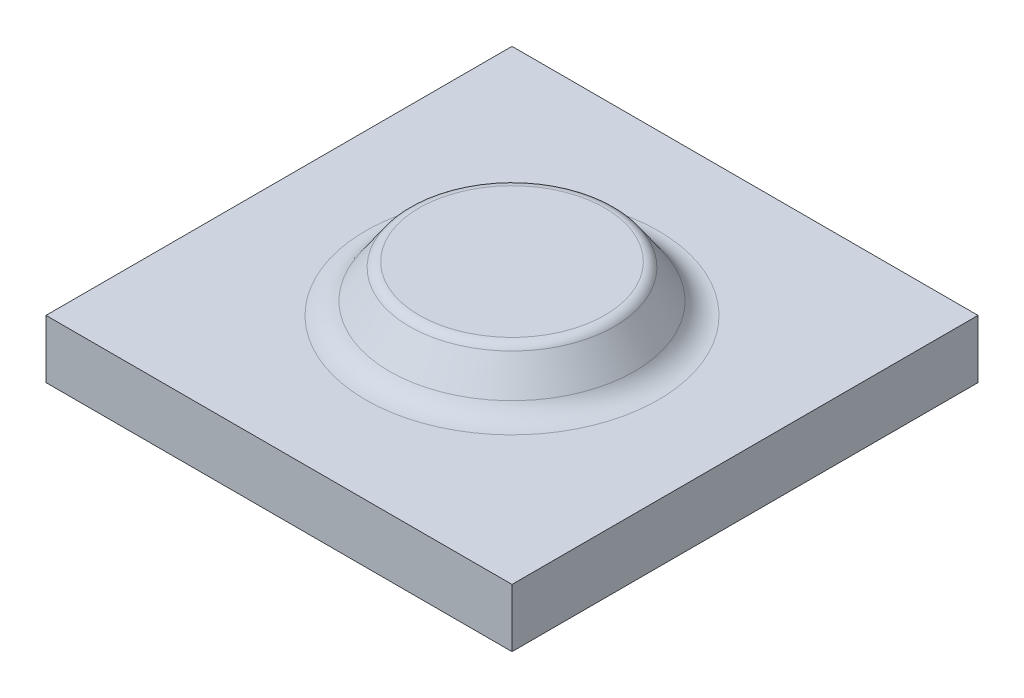
from build123d import *

# Parameters (mm, degrees)
SKETCH_1_W      = 80
SKETCH_1_H      = 80
EXTRUDE_1_DEPTH = 10
FILLET_1_R      = 5
FILLET_2_R      = 2


with BuildPart() as part:
    # 草图1 → 凸台-拉伸1 (new body)
    with BuildSketch(Plane(origin=(0, 0, 0), x_dir=(1, 0, 0), z_dir=(0, 1, 0))):
        Rectangle(SKETCH_1_W, SKETCH_1_H)
    extrude(amount=EXTRUDE_1_DEPTH)

    # 草图2 → 旋转1 (revolve)
    with BuildSketch(Plane.XY):
        Polygon((0, 18), (0, 10), (22.5, 10), (17, 18), align=None)
    revolve(axis=Axis((0, 0, 0), (0, 1, 0)))

    # 圆角1
    fillet_1_edges = [part.edges().sort_by_distance(p)[0] for p in [
        (-22.5, 10, 0),
    ]]
    fillet(fillet_1_edges, radius=FILLET_1_R)

    # 圆角2
    fillet_2_edges = [part.edges().sort_by_distance(p)[0] for p in [
        (-17, 18, 0),
    ]]
    fillet(fillet_2_edges, radius=FILLET_2_R)


solid = part.part
